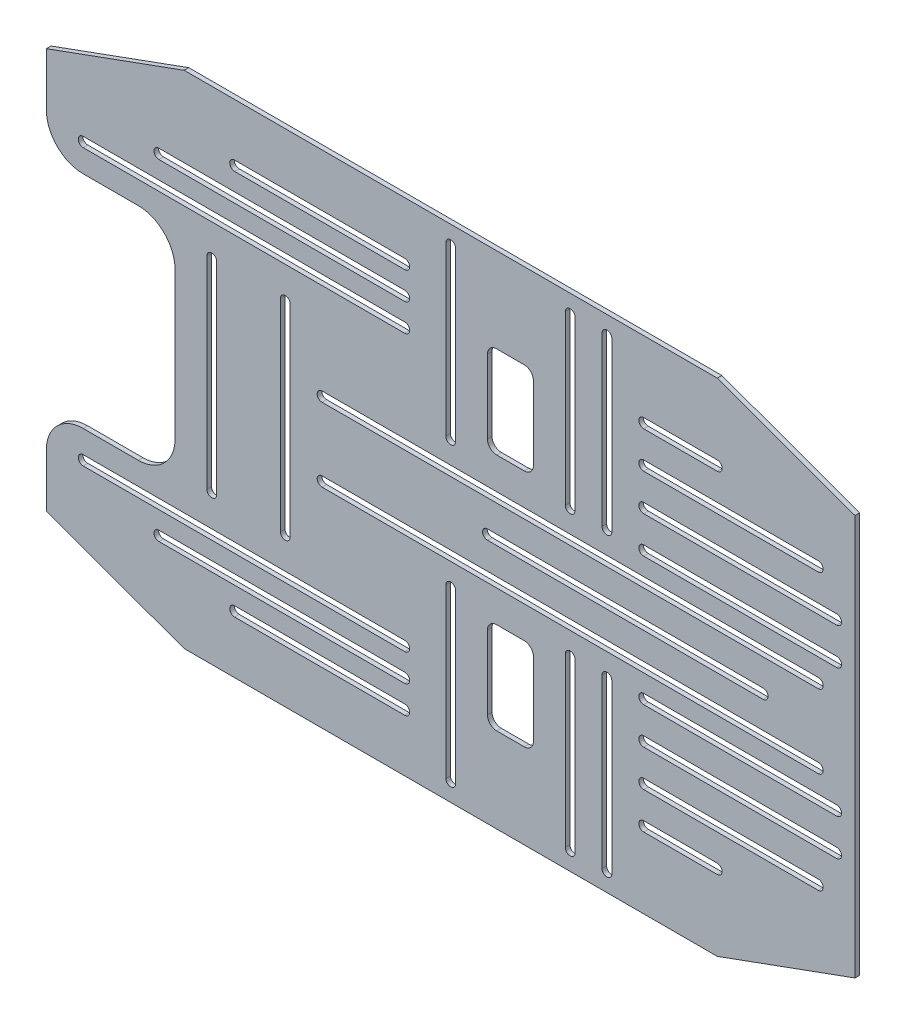
from build123d import *

# Parameters (mm, degrees)
BOSS_EXTRUDE1_DEPTH = 3.175
FILLET3_R           = 25.4
CUT_EXTRUDE3_DEPTH  = 4.175


with BuildPart() as part:
    # Sketch1 → Boss-Extrude1 (new body)
    with BuildSketch(Plane.XY):
        Polygon((-279.4, 138.38935405), (-184.214073546, 173.034198), (184.214073546, 173.034198), (279.4, 138.38935405), (279.4, -138.38935405), (184.214073546, -173.034198), (-184.214073546, -173.034198), (-279.4, -138.38935405), (-279.4, -76.2), (-190.5, -76.2), (-190.5, 76.2), (-279.4, 76.2), align=None)
    extrude(amount=BOSS_EXTRUDE1_DEPTH)

    # Fillet3
    fillet3_edges = [part.edges().sort_by_distance(p)[0] for p in [
        (-279.4, -76.2, 1.5875),
        (-190.5, -76.2, 1.5875),
        (-190.5, 76.2, 1.5875),
        (-279.4, 76.2, 1.5875),
    ]]
    fillet(fillet3_edges, radius=FILLET3_R)

    # Sketch4 → Cut-Extrude3 (cut, through all)
    with BuildSketch(Plane.XY.offset(3.175)):
        with BuildLine():
            Line((-254, 98.6282), (-31.75, 98.6282))
            ThreePointArc((-31.75, 98.6282), (-28.3718, 95.25), (-31.75, 91.8718))
            Line((-31.75, 91.8718), (-254, 91.8718))
            ThreePointArc((-254, 91.8718), (-257.3782, 95.25), (-254, 98.6282))
        make_face()
        with BuildLine():
            Line((-201.660555159, 117.6782), (-31.75, 117.6782))
            ThreePointArc((-31.75, 117.6782), (-28.3718, 114.3), (-31.75, 110.9218))
            Line((-31.75, 110.9218), (-201.660555159, 110.9218))
            ThreePointArc((-201.660555159, 110.9218), (-205.038755159, 114.3), (-201.660555159, 117.6782))
        make_face()
        with BuildLine():
            Line((-149.321110319, 136.7282), (-31.75, 136.7282))
            ThreePointArc((-31.75, 136.7282), (-28.3718, 133.35), (-31.75, 129.9718))
            Line((-31.75, 129.9718), (-149.321110319, 129.9718))
            ThreePointArc((-149.321110319, 129.9718), (-152.699310319, 133.35), (-149.321110319, 136.7282))
        make_face()
        with BuildLine():
            Line((-161.7218, 69.85), (-161.7218, -69.85))
            ThreePointArc((-161.7218, -69.85), (-165.1, -73.2282), (-168.4782, -69.85))
            Line((-168.4782, -69.85), (-168.4782, 69.85))
            ThreePointArc((-168.4782, 69.85), (-165.1, 73.2282), (-161.7218, 69.85))
        make_face()
        with BuildLine():
            Line((-110.9218, 69.85), (-110.9218, -69.85))
            ThreePointArc((-110.9218, -69.85), (-114.3, -73.2282), (-117.6782, -69.85))
            Line((-117.6782, -69.85), (-117.6782, 69.85))
            ThreePointArc((-117.6782, 69.85), (-114.3, 73.2282), (-110.9218, 69.85))
        make_face()
        with BuildLine():
            Line((31.75, 114.3), (50.8, 114.3))
            ThreePointArc((50.8, 114.3), (55.290128061, 112.440128061), (57.15, 107.95))
            Line((57.15, 107.95), (57.15, 57.15))
            ThreePointArc((57.15, 57.15), (55.290128061, 52.659871939), (50.8, 50.8))
            Line((50.8, 50.8), (31.75, 50.8))
            ThreePointArc((31.75, 50.8), (27.259871939, 52.659871939), (25.4, 57.15))
            Line((25.4, 57.15), (25.4, 107.95))
            ThreePointArc((25.4, 107.95), (27.259871939, 112.440128061), (31.75, 114.3))
        make_face()
        with BuildLine():
            Line((3.3782, 160.334198), (3.3782, 44.45))
            ThreePointArc((3.3782, 44.45), (0, 41.0718), (-3.3782, 44.45))
            Line((-3.3782, 44.45), (-3.3782, 160.334198))
            ThreePointArc((-3.3782, 160.334198), (0, 163.712398), (3.3782, 160.334198))
        make_face()
        with BuildLine():
            Line((-88.9, 28.7782), (254, 28.7782))
            ThreePointArc((254, 28.7782), (257.3782, 25.4), (254, 22.0218))
            Line((254, 22.0218), (-88.9, 22.0218))
            ThreePointArc((-88.9, 22.0218), (-92.2782, 25.4), (-88.9, 28.7782))
        make_face()
        with BuildLine():
            Line((79.1718, 44.45), (79.1718, 160.334198))
            ThreePointArc((79.1718, 160.334198), (82.55, 163.712398), (85.9282, 160.334198))
            Line((85.9282, 160.334198), (85.9282, 44.45))
            ThreePointArc((85.9282, 44.45), (82.55, 41.0718), (79.1718, 44.45))
        make_face()
        with BuildLine():
            Line((111.3282, 160.334198), (111.3282, 44.45))
            ThreePointArc((111.3282, 44.45), (107.95, 41.0718), (104.5718, 44.45))
            Line((104.5718, 44.45), (104.5718, 160.334198))
            ThreePointArc((104.5718, 160.334198), (107.95, 163.712398), (111.3282, 160.334198))
        make_face()
        with BuildLine():
            Line((133.35, 124.0282), (184.214073546, 124.0282))
            ThreePointArc((184.214073546, 124.0282), (187.592273546, 120.65), (184.214073546, 117.2718))
            Line((184.214073546, 117.2718), (133.35, 117.2718))
            ThreePointArc((133.35, 117.2718), (129.9718, 120.65), (133.35, 124.0282))
        make_face()
        with BuildLine():
            Line((133.35, 98.6282), (254, 98.6282))
            ThreePointArc((254, 98.6282), (257.3782, 95.25), (254, 91.8718))
            Line((254, 91.8718), (133.35, 91.8718))
            ThreePointArc((133.35, 91.8718), (129.9718, 95.25), (133.35, 98.6282))
        make_face()
        with BuildLine():
            Line((133.35, 73.2282), (266.7, 73.2282))
            ThreePointArc((266.7, 73.2282), (270.0782, 69.85), (266.7, 66.4718))
            Line((266.7, 66.4718), (133.35, 66.4718))
            ThreePointArc((133.35, 66.4718), (129.9718, 69.85), (133.35, 73.2282))
        make_face()
        with BuildLine():
            Line((133.35, 47.8282), (266.7, 47.8282))
            ThreePointArc((266.7, 47.8282), (270.0782, 44.45), (266.7, 41.0718))
            Line((266.7, 41.0718), (133.35, 41.0718))
            ThreePointArc((133.35, 41.0718), (129.9718, 44.45), (133.35, 47.8282))
        make_face()
        with BuildLine():
            Line((-254, -98.6282), (-31.75, -98.6282))
            ThreePointArc((-31.75, -98.6282), (-28.3718, -95.25), (-31.75, -91.8718))
            Line((-31.75, -91.8718), (-254, -91.8718))
            ThreePointArc((-254, -91.8718), (-257.3782, -95.25), (-254, -98.6282))
        make_face()
        with BuildLine():
            Line((-201.660555159, -117.6782), (-31.75, -117.6782))
            ThreePointArc((-31.75, -117.6782), (-28.3718, -114.3), (-31.75, -110.9218))
            Line((-31.75, -110.9218), (-201.660555159, -110.9218))
            ThreePointArc((-201.660555159, -110.9218), (-205.038755159, -114.3), (-201.660555159, -117.6782))
        make_face()
        with BuildLine():
            Line((-149.321110319, -136.7282), (-31.75, -136.7282))
            ThreePointArc((-31.75, -136.7282), (-28.3718, -133.35), (-31.75, -129.9718))
            Line((-31.75, -129.9718), (-149.321110319, -129.9718))
            ThreePointArc((-149.321110319, -129.9718), (-152.699310319, -133.35), (-149.321110319, -136.7282))
        make_face()
        with BuildLine():
            Line((3.3782, -160.334198), (3.3782, -44.45))
            ThreePointArc((3.3782, -44.45), (0, -41.0718), (-3.3782, -44.45))
            Line((-3.3782, -44.45), (-3.3782, -160.334198))
            ThreePointArc((-3.3782, -160.334198), (0, -163.712398), (3.3782, -160.334198))
        make_face()
        with BuildLine():
            Line((-88.9, -28.7782), (254, -28.7782))
            ThreePointArc((254, -28.7782), (257.3782, -25.4), (254, -22.0218))
            Line((254, -22.0218), (-88.9, -22.0218))
            ThreePointArc((-88.9, -22.0218), (-92.2782, -25.4), (-88.9, -28.7782))
        make_face()
        with BuildLine():
            Line((79.1718, -44.45), (79.1718, -160.334198))
            ThreePointArc((79.1718, -160.334198), (82.55, -163.712398), (85.9282, -160.334198))
            Line((85.9282, -160.334198), (85.9282, -44.45))
            ThreePointArc((85.9282, -44.45), (82.55, -41.0718), (79.1718, -44.45))
        make_face()
        with BuildLine():
            Line((111.3282, -160.334198), (111.3282, -44.45))
            ThreePointArc((111.3282, -44.45), (107.95, -41.0718), (104.5718, -44.45))
            Line((104.5718, -44.45), (104.5718, -160.334198))
            ThreePointArc((104.5718, -160.334198), (107.95, -163.712398), (111.3282, -160.334198))
        make_face()
        with BuildLine():
            Line((133.35, -124.0282), (184.214073546, -124.0282))
            ThreePointArc((184.214073546, -124.0282), (187.592273546, -120.65), (184.214073546, -117.2718))
            Line((184.214073546, -117.2718), (133.35, -117.2718))
            ThreePointArc((133.35, -117.2718), (129.9718, -120.65), (133.35, -124.0282))
        make_face()
        with BuildLine():
            Line((133.35, -98.6282), (254, -98.6282))
            ThreePointArc((254, -98.6282), (257.3782, -95.25), (254, -91.8718))
            Line((254, -91.8718), (133.35, -91.8718))
            ThreePointArc((133.35, -91.8718), (129.9718, -95.25), (133.35, -98.6282))
        make_face()
        with BuildLine():
            Line((133.35, -73.2282), (266.7, -73.2282))
            ThreePointArc((266.7, -73.2282), (270.0782, -69.85), (266.7, -66.4718))
            Line((266.7, -66.4718), (133.35, -66.4718))
            ThreePointArc((133.35, -66.4718), (129.9718, -69.85), (133.35, -73.2282))
        make_face()
        with BuildLine():
            Line((133.35, -47.8282), (266.7, -47.8282))
            ThreePointArc((266.7, -47.8282), (270.0782, -44.45), (266.7, -41.0718))
            Line((266.7, -41.0718), (133.35, -41.0718))
            ThreePointArc((133.35, -41.0718), (129.9718, -44.45), (133.35, -47.8282))
        make_face()
        with BuildLine():
            Line((57.15, -107.95), (57.15, -57.15))
            ThreePointArc((57.15, -57.15), (55.290128061, -52.659871939), (50.8, -50.8))
            Line((50.8, -50.8), (31.75, -50.8))
            ThreePointArc((31.75, -50.8), (27.259871939, -52.659871939), (25.4, -57.15))
            Line((25.4, -57.15), (25.4, -107.95))
            ThreePointArc((25.4, -107.95), (27.259871939, -112.440128061), (31.75, -114.3))
            Line((31.75, -114.3), (50.8, -114.3))
            ThreePointArc((50.8, -114.3), (55.290128061, -112.440128061), (57.15, -107.95))
        make_face()
        with BuildLine():
            Line((25.4, 3.3782), (215.9, 3.3782))
            ThreePointArc((215.9, 3.3782), (219.2782, 0), (215.9, -3.3782))
            Line((215.9, -3.3782), (25.4, -3.3782))
            ThreePointArc((25.4, -3.3782), (22.0218, 0), (25.4, 3.3782))
        make_face()
    extrude(amount=-CUT_EXTRUDE3_DEPTH, mode=Mode.SUBTRACT)


solid = part.part
